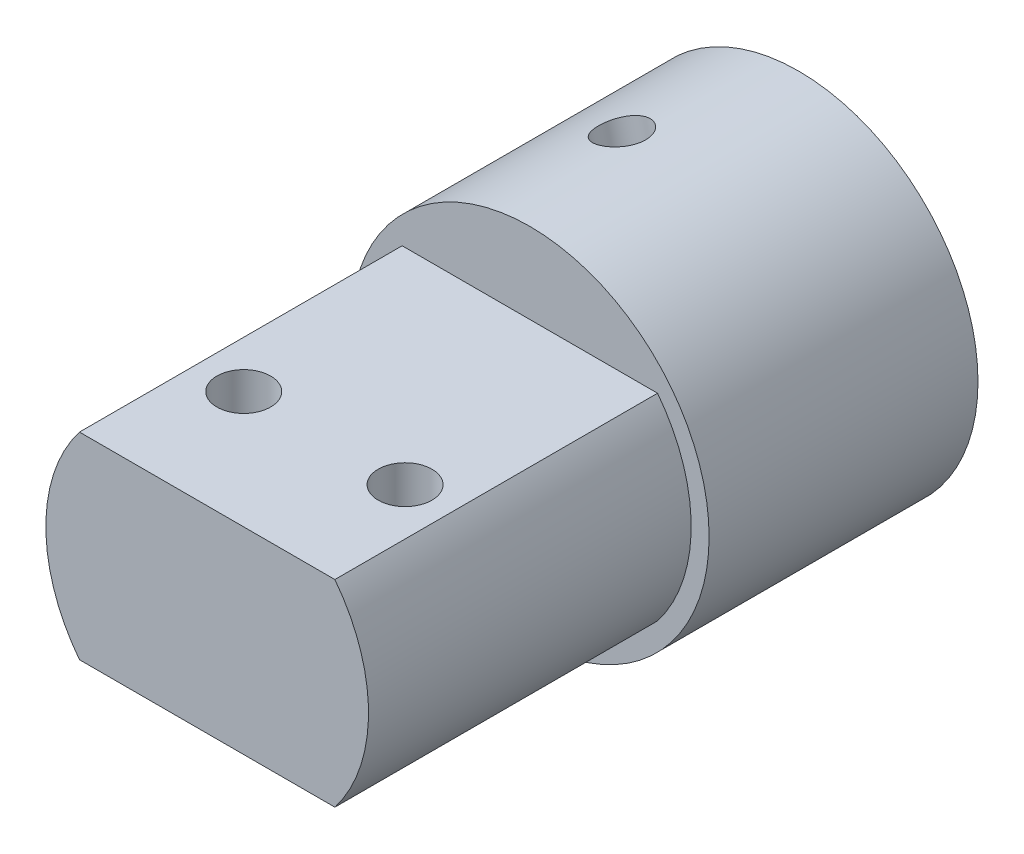
from build123d import *

# Parameters (mm, degrees)
SKETCH_1_R          = 5.25
EXTRUDE_1_DEPTH     = 15
CUT_EXTRUDE_1_DEPTH = 10
EXTRUDE_2_DEPTH     = 18
SKETCH_4_R          = 1.5
CUT_EXTRUDE_2_DEPTH = 14.5
SKETCH_5_R          = 14
SKETCH_5_R_2        = 5.25
EXTRUDE_3_DEPTH     = 15
SKETCH_6_R          = 18.043638251
SKETCH_6_R_2        = 10
CUT_EXTRUDE_3_DEPTH = 15
SKETCH_7_R          = 6.986522344
EXTRUDE_4_DEPTH     = 15
SKETCH_8_R          = 1.35
CUT_EXTRUDE_4_DEPTH = 15


with BuildPart() as part:
    # 草图1 → 凸台-拉伸1 (new body)
    with BuildSketch(Plane.XY):
        with BuildLine():
            Line((-11.489125293, -8), (11.489125293, -8))
            ThreePointArc((11.489125293, -8), (0, 14), (-11.489125293, -8))
        make_face()
        Circle(SKETCH_1_R, mode=Mode.SUBTRACT)
    extrude(amount=EXTRUDE_1_DEPTH)

    # 草图2 → 切除-拉伸1 (cut)
    with BuildSketch(Plane.XY.offset(15)):
        with BuildLine():
            Line((-13.416407865, 4), (13.416407865, 4))
            ThreePointArc((13.416407865, 4), (0, 14), (-13.416407865, 4))
        make_face()
    extrude(amount=-CUT_EXTRUDE_1_DEPTH, mode=Mode.SUBTRACT)

    # 草图3 → 凸台-拉伸2 (add)
    with BuildSketch(Plane.XY.offset(15)):
        with BuildLine():
            Line((-7.123903424, 5.5), (7.123903424, 5.5))
            ThreePointArc((7.123903424, 5.5), (9, 0), (7.123903424, -5.5))
            Line((7.123903424, -5.5), (-7.123903424, -5.5))
            ThreePointArc((-7.123903424, -5.5), (-9, 0), (-7.123903424, 5.5))
        make_face()
    extrude(amount=EXTRUDE_2_DEPTH)

    # 草图4 → 切除-拉伸2 (cut, through all)
    with BuildSketch(Plane(origin=(0, 5.5, 0), x_dir=(1, 0, 0), z_dir=(0, 1, 0))):
        with Locations((4.5, -26.46)):
            Circle(SKETCH_4_R)
        with Locations((-4.5, -26.46)):
            Circle(SKETCH_4_R)
    extrude(amount=-CUT_EXTRUDE_2_DEPTH, mode=Mode.SUBTRACT)

    # 草图5 → 凸台-拉伸3 (add)
    with BuildSketch(Plane(origin=(0, 0, 0), x_dir=(-1, 0, 0), z_dir=(0, 0, -1))):
        Circle(SKETCH_5_R)
        Circle(SKETCH_5_R_2, mode=Mode.SUBTRACT)
    extrude(amount=-EXTRUDE_3_DEPTH)

    # 草图6 → 切除-拉伸3 (cut)
    with BuildSketch(Plane(origin=(0, 0, 0), x_dir=(-1, 0, 0), z_dir=(0, 0, -1))):
        Circle(SKETCH_6_R)
        Circle(SKETCH_6_R_2, mode=Mode.SUBTRACT)
    extrude(amount=-CUT_EXTRUDE_3_DEPTH, mode=Mode.SUBTRACT)

    # 草图7 → 凸台-拉伸4 (add)
    with BuildSketch(Plane(origin=(0, 0, 0), x_dir=(-1, 0, 0), z_dir=(0, 0, -1))):
        Circle(SKETCH_7_R)
        with BuildLine():
            Line((-1.985312345, 4.588957931), (3.849512157, 3.190808072))
            ThreePointArc((3.849512157, 3.190808072), (-1.165124883, -4.862353752), (-1.985312345, 4.588957931))
        make_face(mode=Mode.SUBTRACT)
    extrude(amount=-EXTRUDE_4_DEPTH)

    # 草图8 → 切除-拉伸4 (cut)
    with BuildSketch(Plane(origin=(-0.932099906, 3.889883001, 0), x_dir=(0.97247075, 0.233024977, 0), z_dir=(0.233024977, -0.97247075, 0))):
        with Locations((0, 7.544256547)):
            Circle(SKETCH_8_R)
    extrude(amount=-CUT_EXTRUDE_4_DEPTH, mode=Mode.SUBTRACT)


solid = part.part
